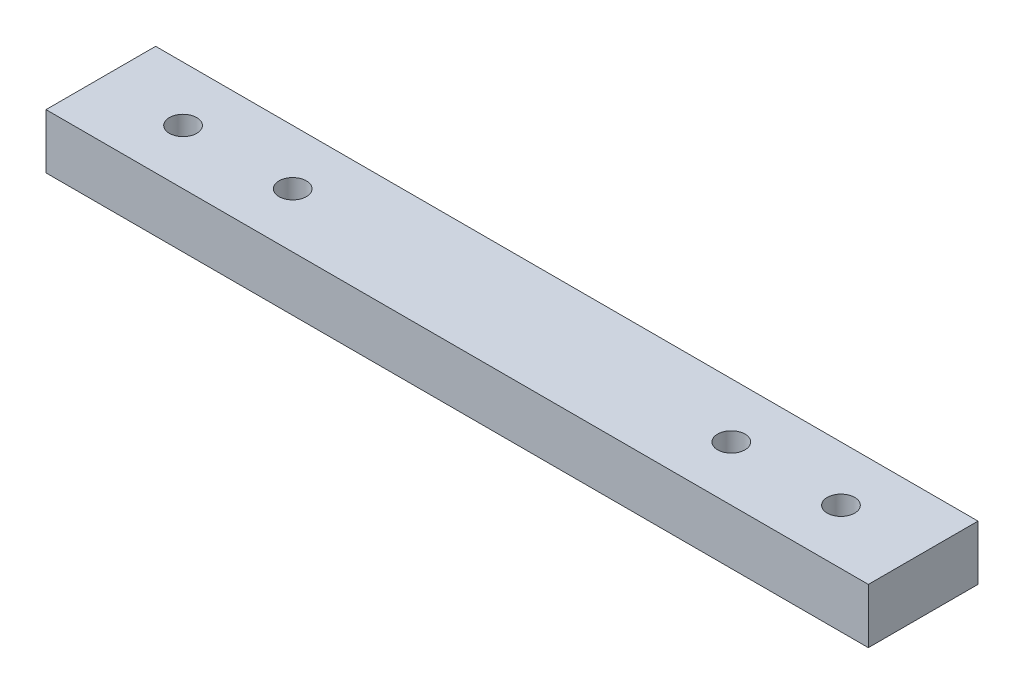
from build123d import *

# Parameters (mm, degrees)
SKETCH1_W           = 150
SKETCH1_H           = 20
SKETCH1_R           = 2.5
BOSS_EXTRUDE1_DEPTH = 10


with BuildPart() as part:
    # Sketch1 → Boss-Extrude1 (new body)
    with BuildSketch(Plane(origin=(0, 0, 0), x_dir=(1, 0, 0), z_dir=(0, 1, 0))):
        with Locations((75, 10)):
            Rectangle(SKETCH1_W, SKETCH1_H)
        with Locations((15, 10)):
            Circle(SKETCH1_R, mode=Mode.SUBTRACT)
        with Locations((35, 10)):
            Circle(SKETCH1_R, mode=Mode.SUBTRACT)
        with Locations((115, 10)):
            Circle(SKETCH1_R, mode=Mode.SUBTRACT)
        with Locations((135, 10)):
            Circle(SKETCH1_R, mode=Mode.SUBTRACT)
    extrude(amount=BOSS_EXTRUDE1_DEPTH)


solid = part.part
